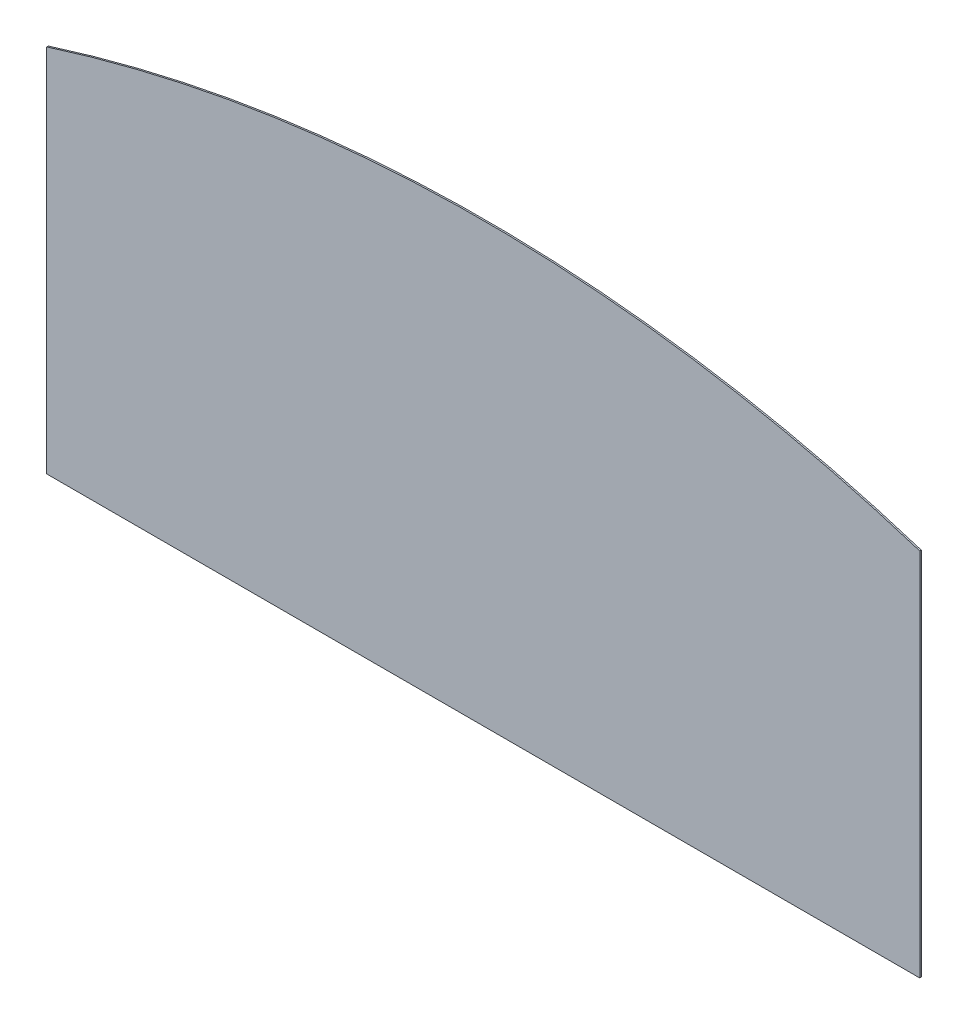
from build123d import *

# Parameters (mm, degrees)
BOSS_EXTRUDE1_DEPTH = 6.35


with BuildPart() as part:
    # Sketch1 → Boss-Extrude1 (new body)
    with BuildSketch(Plane.XY):
        with BuildLine():
            Line((0, 0), (3657.6, 0))
            Line((3657.6, 0), (3657.6, 1549.4))
            ThreePointArc((3657.6, 1549.4), (1828.8, 1834.429842637), (0, 1549.4))
            Line((0, 1549.4), (0, 0))
        make_face()
    extrude(amount=BOSS_EXTRUDE1_DEPTH)


solid = part.part
